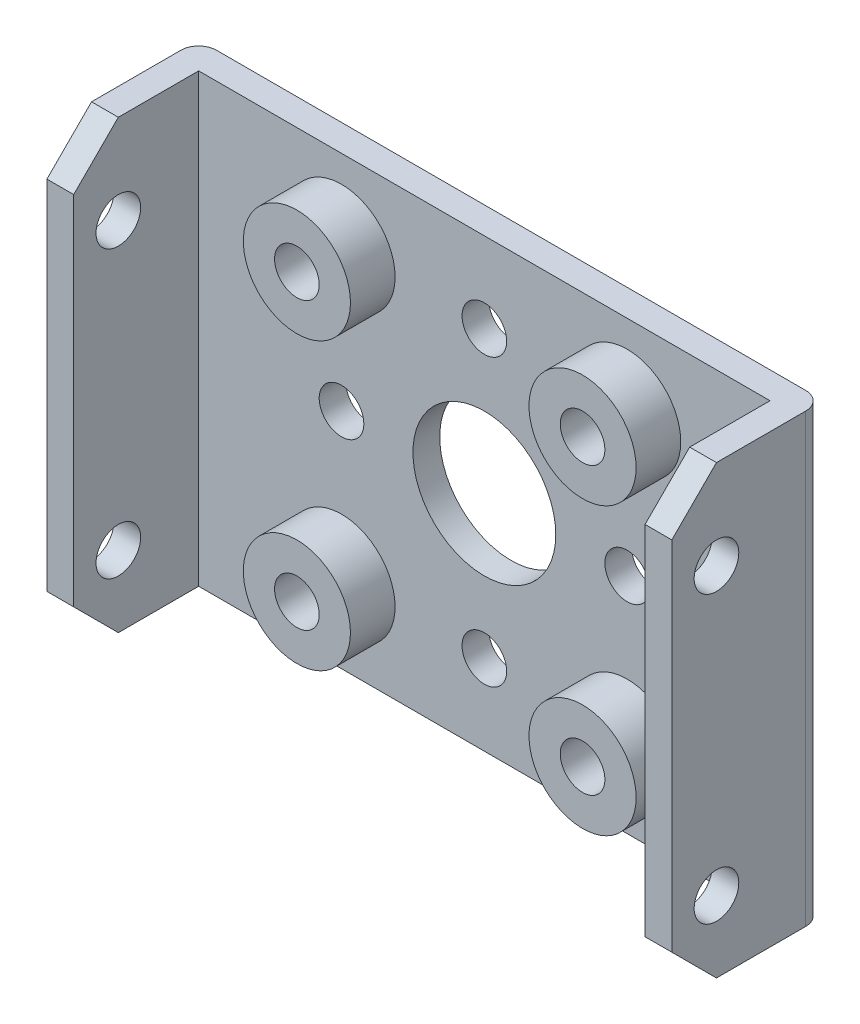
from build123d import *

# Parameters (mm, degrees)
SKETCH1_W               = 35
SKETCH1_H               = 25
BOSS_EXTRUDE1_DEPTH     = 8.5
SKETCH3_W               = 32
SKETCH3_H               = 25
CUT_EXTRUDE1_DEPTH      = 7
FILLET1_R               = 1
CHAMFER1_SIZE           = 2.5
SKETCH4_R               = 1.25
CUT_EXTRUDE2_DEPTH      = 35
SKETCH5_R               = 3
BOSS_EXTRUDE3_DEPTH     = 2.5
SKETCH7_R               = 4
SKETCH7_R_2             = 1.25
CUT_EXTRUDE3_DEPTH      = 2.5
CUT_EXTRUDE3_DEPTH_BACK = 1.5


with BuildPart() as part:
    # Sketch1 → Boss-Extrude1 (new body)
    with BuildSketch(Plane.XY):
        with Locations((17.5, 12.5)):
            Rectangle(SKETCH1_W, SKETCH1_H)
    extrude(amount=BOSS_EXTRUDE1_DEPTH)

    # Sketch3 → Cut-Extrude1 (cut)
    with BuildSketch(Plane.XY.offset(8.5)):
        with Locations((17.5, 12.5)):
            Rectangle(SKETCH3_W, SKETCH3_H)
    extrude(amount=-CUT_EXTRUDE1_DEPTH, mode=Mode.SUBTRACT)

    # Fillet1
    fillet1_edges = [part.edges().sort_by_distance(p)[0] for p in [
        (0, 12.5, 0),
        (35, 12.5, 0),
    ]]
    fillet(fillet1_edges, radius=FILLET1_R)

    # Chamfer1
    chamfer1_edges = [part.edges().sort_by_distance(p)[0] for p in [
        (0.75, 0, 8.5),
        (0.75, 25, 8.5),
        (34.25, 0, 8.5),
        (34.25, 25, 8.5),
    ]]
    chamfer(chamfer1_edges, length=CHAMFER1_SIZE)

    # Sketch4 → Cut-Extrude2 (cut)
    with BuildSketch(Plane.ZY):
        with Locations((6, 20)):
            Circle(SKETCH4_R)
        with Locations((6, 4)):
            Circle(SKETCH4_R)
    extrude(amount=-CUT_EXTRUDE2_DEPTH, mode=Mode.SUBTRACT)

    # Sketch5 → Boss-Extrude3 (add)
    with BuildSketch(Plane.XY.offset(1.5)):
        with Locations((9.5, 4.5)):
            Circle(SKETCH5_R)
        with Locations((25.5, 4.5)):
            Circle(SKETCH5_R)
        with Locations((25.499999171, 20.5)):
            Circle(SKETCH5_R)
        with Locations((9.499999171, 20.5)):
            Circle(SKETCH5_R)
    extrude(amount=BOSS_EXTRUDE3_DEPTH)

    # Sketch7 → Cut-Extrude3 (cut, two sides)
    with BuildSketch(Plane.XY.offset(1.5)) as cut_extrude3_sk:
        with Locations((17.5, 12.5)):
            Circle(SKETCH7_R)
        with Locations((9.5, 4.5)):
            Circle(SKETCH7_R_2)
        with Locations((17.5, 4.5)):
            Circle(SKETCH7_R_2)
        with Locations((25.5, 4.5)):
            Circle(SKETCH7_R_2)
        with Locations((25.5, 12.5)):
            Circle(SKETCH7_R_2)
        with Locations((17.5, 20.5)):
            Circle(SKETCH7_R_2)
        with Locations((25.5, 20.5)):
            Circle(SKETCH7_R_2)
        with Locations((9.5, 12.5)):
            Circle(SKETCH7_R_2)
        with Locations((9.5, 20.5)):
            Circle(SKETCH7_R_2)
    extrude(amount=CUT_EXTRUDE3_DEPTH, mode=Mode.SUBTRACT)
    extrude(cut_extrude3_sk.sketch, amount=-CUT_EXTRUDE3_DEPTH_BACK, mode=Mode.SUBTRACT)


solid = part.part
